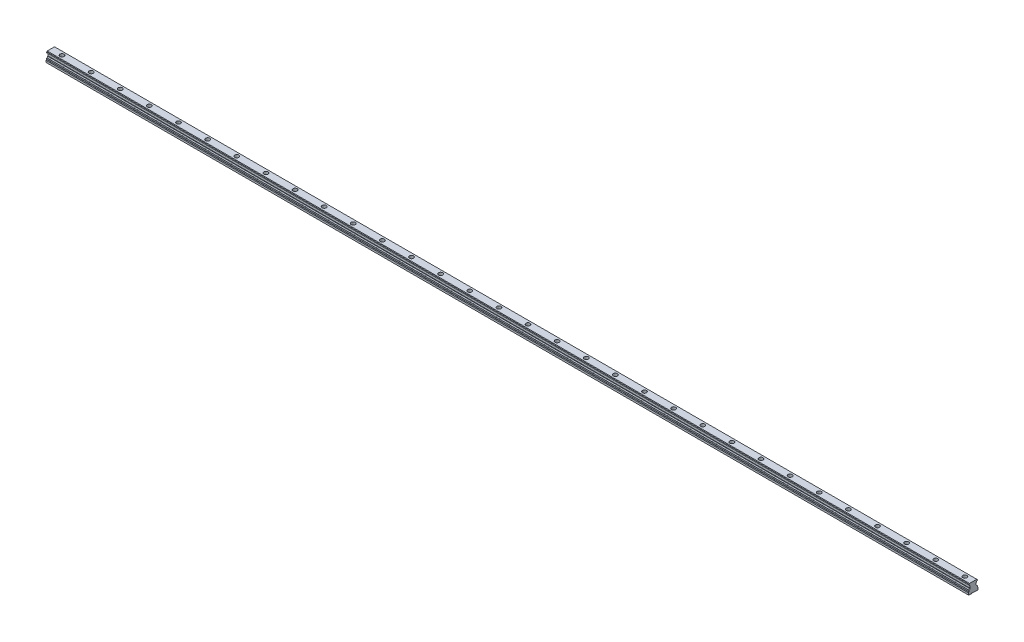
from build123d import *

# Parameters (mm, degrees)
BOSS_EXTRUDE5_DEPTH = 1900
SKETCH8_R           = 4.25
CUT_EXTRUDE1_DEPTH  = 9
SKETCH9_R           = 3
CUT_EXTRUDE2_DEPTH  = 12.3
LPATTERN1_COUNT     = 35
LPATTERN1_PITCH     = 60


with BuildPart() as part:
    # Sketch7 → Boss-Extrude5 (new body)
    with BuildSketch(Plane(origin=(58.5, 0, 0), x_dir=(0, 0, -1), z_dir=(1, 0, 0))):
        with BuildLine():
            Line((-7.709038211, 8.883084864), (-8.5, 8.601077183))
            Line((-8.5, 8.601077183), (-8.5, 6.104700538))
            ThreePointArc((-8.5, 6.104700538), (-8.566987298, 5.854700538), (-8.75, 5.671687836))
            Line((-8.75, 5.671687836), (-10, 4.95))
            Line((-10, 4.95), (-10, 1))
            Line((-10, 1), (-9, 0))
            Line((-9, 0), (-4, 0))
            Line((-4, 0), (-3.5, 0.5))
            Line((-3.5, 0.5), (3.5, 0.5))
            Line((3.5, 0.5), (4, 0))
            Line((4, 0), (9, 0))
            Line((9, 0), (10, 1))
            Line((10, 1), (10, 4.95))
            Line((10, 4.95), (8.75, 5.671687836))
            ThreePointArc((8.75, 5.671687836), (8.566987298, 5.854700538), (8.5, 6.104700538))
            Line((8.5, 6.104700538), (8.5, 8.46691323))
            Line((8.5, 8.46691323), (8.084678947, 8.882234283))
            ThreePointArc((8.084678947, 8.882234283), (6.941822875, 9.249266637), (6.503340774, 10.366659226))
            Line((6.503340774, 10.366659226), (6, 10.87))
            Line((6, 10.87), (6, 14.93))
            Line((6, 14.93), (6.503340774, 15.433340774))
            ThreePointArc((6.503340774, 15.433340774), (6.813545517, 16.412959034), (7.709038211, 16.916915136))
            Line((7.709038211, 16.916915136), (8.5, 17.198922817))
            Line((8.5, 17.198922817), (8.5, 19.3))
            Line((8.5, 19.3), (7.5, 20.3))
            Line((7.5, 20.3), (-7.5, 20.3))
            Line((-7.5, 20.3), (-8.5, 19.3))
            Line((-8.5, 19.3), (-8.5, 17.33308677))
            Line((-8.5, 17.33308677), (-8.084678947, 16.917765717))
            ThreePointArc((-8.084678947, 16.917765717), (-6.941822875, 16.550733363), (-6.503340774, 15.433340774))
            Line((-6.503340774, 15.433340774), (-6, 14.93))
            Line((-6, 14.93), (-6, 10.87))
            Line((-6, 10.87), (-6.503340774, 10.366659226))
            ThreePointArc((-6.503340774, 10.366659226), (-6.813545517, 9.387040966), (-7.709038211, 8.883084864))
        make_face()
    extrude(amount=BOSS_EXTRUDE5_DEPTH)

    # Sketch8 → Cut-Extrude1 (cut)
    with BuildSketch(Plane(origin=(0, 20.3, 0), x_dir=(1, 0, 0), z_dir=(0, 1, 0))):
        with Locations((1941.491679108, 0)):
            Circle(SKETCH8_R)
    cut_extrude1 = extrude(amount=-CUT_EXTRUDE1_DEPTH, mode=Mode.SUBTRACT)

    # Sketch9 → Cut-Extrude2 (cut, through all)
    with BuildSketch(Plane(origin=(0, 11.3, 0), x_dir=(1, 0, 0), z_dir=(0, 1, 0))):
        with Locations((1941.491679108, 0)):
            Circle(SKETCH9_R)
    cut_extrude2 = extrude(amount=-CUT_EXTRUDE2_DEPTH, mode=Mode.SUBTRACT)

    # LPattern1: Cut-Extrude1, Cut-Extrude2 ×35
    with Locations(*[(-i * LPATTERN1_PITCH, 0, 0) for i in range(1, LPATTERN1_COUNT)]):
        add(cut_extrude1, mode=Mode.SUBTRACT)
        add(cut_extrude2, mode=Mode.SUBTRACT)


solid = part.part
